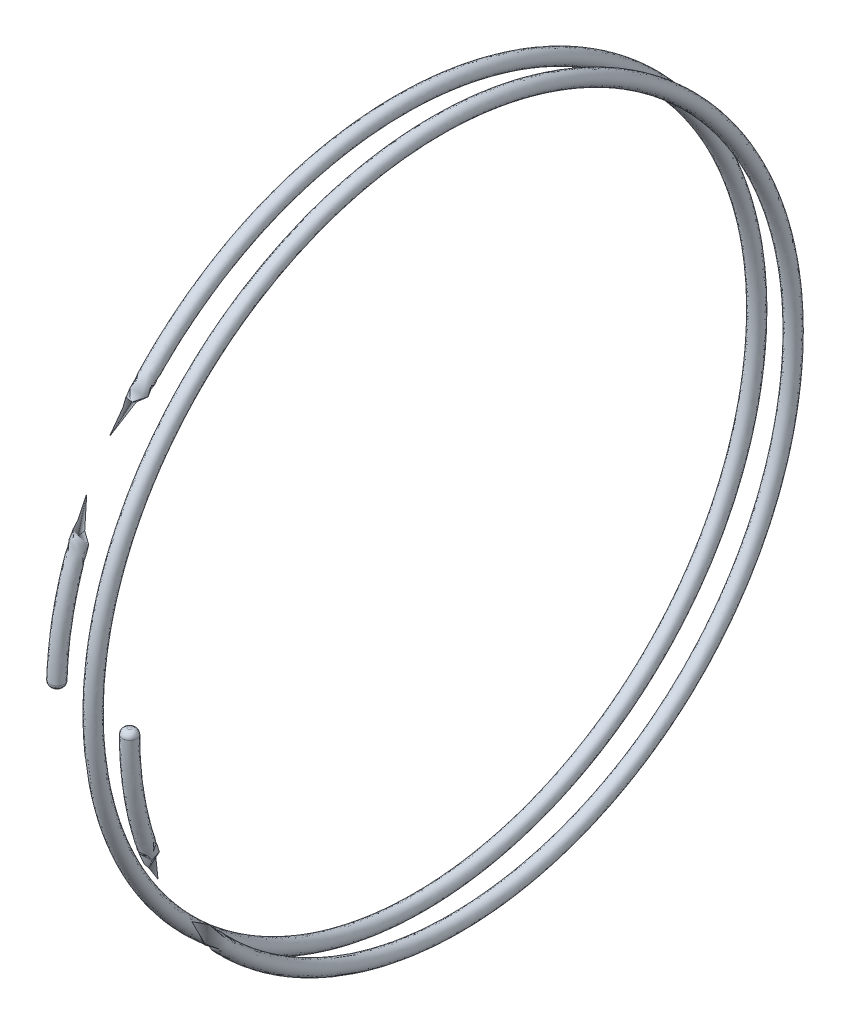
from build123d import *

# Parameters (mm, degrees)
SWEEP1_PITCH  = 0.505
SWEEP1_HEIGHT = 1.01
SWEEP1_RADIUS = 4.725
SKETCH2_R     = 0.1
FILLET1_R     = 0.075


with BuildPart() as part:
    # Sweep1: sweep along a helix
    with BuildLine() as sweep1_path:
        Helix(SWEEP1_PITCH, SWEEP1_HEIGHT, SWEEP1_RADIUS, center=(0, 0, 0), direction=(1, 0, 0), lefthand=True)
    # Sketch2 → Sweep1 (sweep)
    with BuildSketch(Plane(origin=(1.01, 0, 4.725), x_dir=(-0.989160768, 0.016825833, 0.145869349), z_dir=(0.01700775, 0.999855358, 0))):
        Circle(SKETCH2_R)
    sweep(path=sweep1_path.line, is_frenet=True)

    # Fillet1
    fillet1_edges = [part.edges().sort_by_distance(p)[0] for p in [
        (0.098916077, -0.001682583, 4.710413065),
        (1.108916077, -0.001682583, 4.710413065),
    ]]
    fillet(fillet1_edges, radius=FILLET1_R)


solid = part.part
